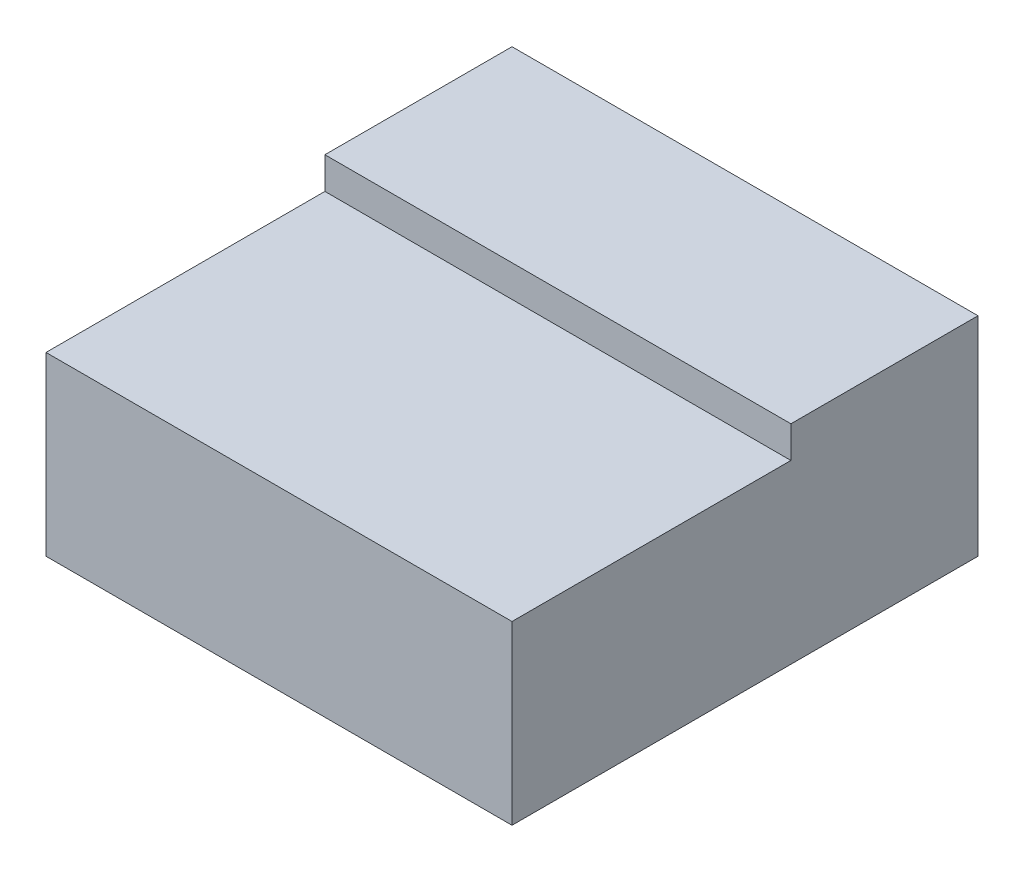
from build123d import *

# Parameters (mm, degrees)
BOSS_EXTRUDE1_DEPTH       = 13.2
F_1_5MM_DOWEL_HOLE1_D     = 1.5
F_1_5MM_DOWEL_HOLE1_DEPTH = 6
F_1_5MM_DOWEL_HOLE1_TIP   = 0.450645464
F_1_5MM_DOWEL_HOLE7_D     = 1.5
F_1_5MM_DOWEL_HOLE7_DEPTH = 6
F_1_5MM_DOWEL_HOLE7_TIP   = 0.450645464


with BuildPart() as part:
    # Sketch3 → Boss-Extrude1 (new body)
    with BuildSketch(Plane(origin=(0, 0, 0), x_dir=(0, 0, -1), z_dir=(1, 0, 0))):
        Polygon((0, 0), (13.2, 0), (13.2, 5), (13.2, 5.9), (7.9, 5.9), (7.9, 5), (0, 5), align=None)
    extrude(amount=BOSS_EXTRUDE1_DEPTH)

    # Ø1.5mm Dowel Hole1
    with Locations(Plane(origin=(0, 0, -13.2), x_dir=(-1, 0, 0), z_dir=(0, 0, -1))):
        with Locations((-3.6, 2.95)):
            Hole(F_1_5MM_DOWEL_HOLE1_D / 2, depth=F_1_5MM_DOWEL_HOLE1_DEPTH)
            with Locations((0, 0, -(F_1_5MM_DOWEL_HOLE1_DEPTH + F_1_5MM_DOWEL_HOLE1_TIP / 2))):  # 118° drill point
                Cone(0, F_1_5MM_DOWEL_HOLE1_D / 2, F_1_5MM_DOWEL_HOLE1_TIP, mode=Mode.SUBTRACT)

    # Ø1.5mm Dowel Hole7
    with Locations(Plane(origin=(0, 0, -13.2), x_dir=(-1, 0, 0), z_dir=(0, 0, -1))):
        with Locations((-9.6, 2.95)):
            Hole(F_1_5MM_DOWEL_HOLE7_D / 2, depth=F_1_5MM_DOWEL_HOLE7_DEPTH)
            with Locations((0, 0, -(F_1_5MM_DOWEL_HOLE7_DEPTH + F_1_5MM_DOWEL_HOLE7_TIP / 2))):  # 118° drill point
                Cone(0, F_1_5MM_DOWEL_HOLE7_D / 2, F_1_5MM_DOWEL_HOLE7_TIP, mode=Mode.SUBTRACT)


solid = part.part
